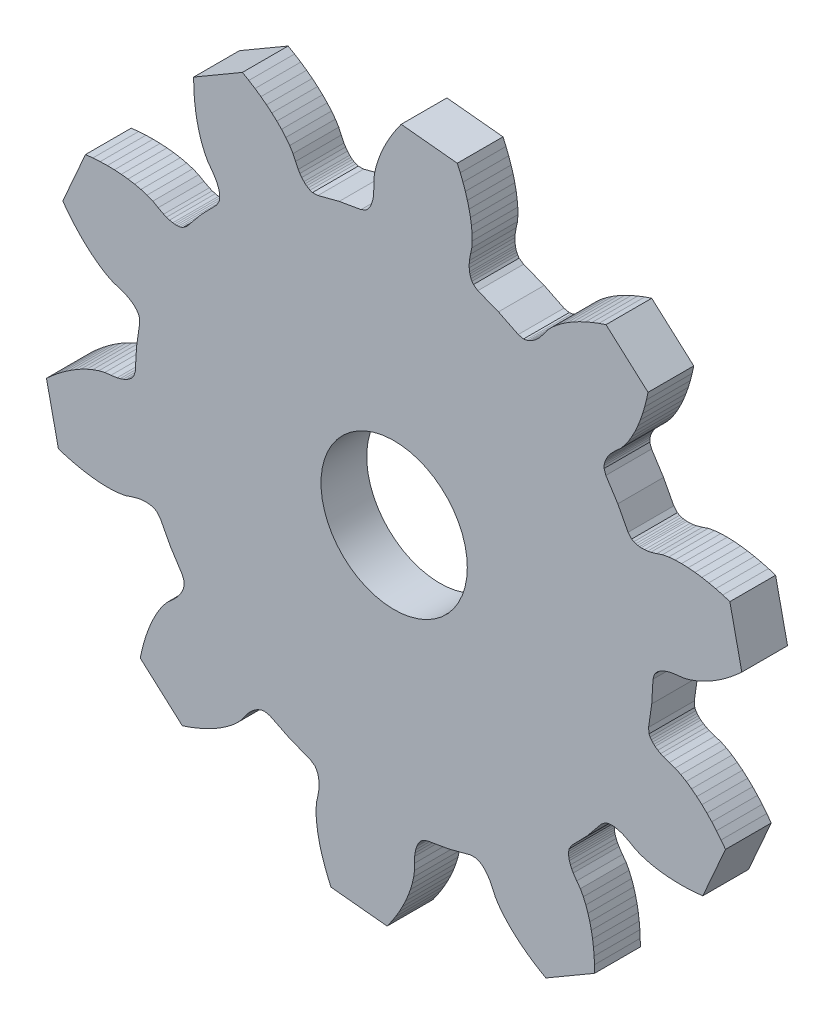
from build123d import *

# Parameters (mm, degrees)
SKETCH1_R           = 5.08
BOSS_EXTRUDE1_DEPTH = 3.175


with BuildPart() as part:
    # Sketch1 → Boss-Extrude1 (new body)
    with BuildSketch(Plane.XY):
        Polygon((8.111998, 16.660876), (7.864348, 16.943578), (7.710424, 17.02816), (7.572502, 17.077944), (7.443216, 17.108932), (7.319772, 17.127474), (7.200392, 17.136618), (6.97103, 17.133824), (6.750812, 17.109948), (6.537198, 17.069816), (6.126226, 16.951198), (5.722366, 16.815308), (5.295138, 16.737584), (4.853432, 16.697452), (4.400804, 16.687546), (3.93954, 16.704564), (3.470402, 16.746474), (2.994914, 16.812006), (2.514092, 16.900144), (2.02819, 17.010888), (1.538478, 17.143222), (1.045718, 17.297146), (0.215646, 21.122894), (0.600456, 21.467064), (0.991362, 21.79066), (1.387602, 22.092412), (1.788668, 22.37232), (2.194306, 22.62886), (2.603754, 22.86127), (3.016758, 23.068026), (3.43281, 23.246334), (3.851402, 23.392892), (4.27228, 23.499318), (4.696206, 23.543006), (5.119624, 23.605236), (5.330444, 23.657052), (5.540756, 23.726902), (5.750814, 23.819358), (5.855462, 23.87727), (5.960364, 23.945088), (6.065012, 24.026876), (6.16966, 24.129492), (6.274816, 24.270208), (6.38302, 24.630126), (6.47192, 26.161238), (6.690614, 27.679396), (6.656578, 28.053538), (6.581648, 28.212542), (6.499352, 28.333954), (6.413246, 28.435046), (6.324092, 28.522422), (6.232906, 28.599892), (6.045708, 28.732734), (5.85343, 28.84297), (5.657342, 28.935934), (5.255006, 29.081476), (4.848352, 29.208984), (4.456938, 29.397198), (4.075938, 29.624528), (3.704082, 29.882338), (3.340862, 30.167326), (2.986024, 30.476698), (2.639822, 30.809184), (2.30251, 31.163514), (1.974596, 31.538418), (1.656334, 31.933388), (1.347978, 32.347662), (2.925318, 35.930586), (3.438906, 35.98291), (3.945128, 36.014914), (4.443222, 36.02609), (4.932172, 36.016692), (5.411216, 35.985958), (5.879084, 35.93338), (6.334506, 35.857688), (6.775958, 35.757612), (7.2009, 35.630104), (7.603998, 35.468814), (7.972552, 35.254946), (8.35152, 35.056572), (8.552688, 34.97453), (8.763762, 34.90722), (8.988044, 34.858706), (9.106916, 34.843974), (9.23163, 34.83737), (9.364472, 34.841942), (9.509506, 34.863278), (9.677146, 34.915348), (9.976358, 35.142932), (10.948162, 36.32962), (12.017502, 37.428932), (12.20978, 37.751766), (12.242546, 37.924486), (12.247372, 38.071044), (12.236958, 38.203378), (12.216384, 38.326568), (12.18819, 38.4429), (12.114784, 38.660324), (12.024106, 38.862508), (11.919966, 39.053008), (11.679936, 39.407084), (11.425936, 39.749476), (11.219942, 40.131746), (11.045444, 40.539416), (10.896092, 40.966644), (10.7696, 41.41089), (10.664444, 41.869868), (10.579862, 42.342308), (10.515346, 42.82694), (10.470388, 43.323256), (10.444988, 43.829732), (10.438892, 44.346114), (13.821156, 46.317662), (14.267434, 46.058074), (14.695678, 45.786294), (15.10538, 45.50283), (15.49527, 45.207682), (15.86484, 44.901358), (16.212312, 44.583604), (16.536416, 44.254674), (16.834866, 43.914314), (17.103344, 43.561508), (17.334738, 43.19397), (17.507204, 42.804334), (17.697196, 42.421048), (17.81175, 42.23639), (17.943068, 42.057828), (18.095976, 41.886886), (18.183352, 41.805098), (18.28038, 41.726358), (18.390616, 41.65219), (18.52041, 41.584118), (18.68678, 41.527476), (19.062446, 41.535858), (20.54606, 41.924732), (22.057614, 42.18559), (22.403054, 42.333672), (22.530816, 42.454068), (22.620986, 42.569892), (22.690328, 42.683176), (22.746208, 42.794936), (22.791674, 42.905426), (22.86, 43.124628), (22.905466, 43.34129), (22.933152, 43.556936), (22.947376, 43.984418), (22.942804, 44.41063), (23.00097, 44.840906), (23.099522, 45.273468), (23.229824, 45.706792), (23.388574, 46.14037), (23.573232, 46.57344), (23.782528, 47.005494), (24.015192, 47.43577), (24.270462, 47.863506), (24.547576, 48.288194), (24.84628, 48.70958), (28.74137, 48.316642), (28.949904, 47.844202), (29.136594, 47.372524), (29.30144, 46.90237), (29.443426, 46.434502), (29.562298, 45.969428), (29.656786, 45.508164), (29.72562, 45.051472), (29.766768, 44.600876), (29.776674, 44.157392), (29.747972, 43.724068), (29.65831, 43.307508), (29.586936, 42.885614), (29.570934, 42.668952), (29.572204, 42.447464), (29.595572, 42.219118), (29.617924, 42.10177), (29.650436, 41.98112), (29.695648, 41.856152), (29.760926, 41.724834), (29.862272, 41.581324), (30.170882, 41.367202), (31.599886, 40.809672), (32.976058, 40.132508), (33.34258, 40.049196), (33.516824, 40.071294), (33.65754, 40.112188), (33.780476, 40.162988), (33.89122, 40.220646), (33.993074, 40.283384), (34.17697, 40.42029), (34.341308, 40.569134), (34.490406, 40.727122), (34.753042, 41.064688), (34.99993, 41.411906), (35.300158, 41.726104), (35.633914, 42.01795), (35.994086, 42.292016), (36.377372, 42.549572), (36.781486, 42.79138), (37.20465, 43.017948), (37.645594, 43.229022), (38.103556, 43.42511), (38.57752, 43.605958), (39.066724, 43.771058), (41.986962, 41.163748), (41.877996, 40.65905), (41.752012, 40.167814), (41.608756, 39.690548), (41.448736, 39.228522), (41.271444, 38.782498), (41.07688, 38.353746), (40.864282, 37.94379), (40.632634, 37.554916), (40.380158, 37.190426), (40.102028, 36.85667), (39.784528, 36.57219), (39.478712, 36.273232), (39.338758, 36.107116), (39.209472, 35.927284), (39.094156, 35.72891), (39.043102, 35.620452), (38.998398, 35.503866), (38.961822, 35.376358), (38.937184, 35.231832), (38.934898, 35.056064), (39.05885, 34.701226), (39.887144, 33.410398), (40.602408, 32.05353), (40.850058, 31.770828), (41.003982, 31.686246), (41.141904, 31.636462), (41.27119, 31.605474), (41.394634, 31.586932), (41.51376, 31.577788), (41.743376, 31.580582), (41.963594, 31.604458), (42.177208, 31.64459), (42.58818, 31.763208), (42.99204, 31.899098), (43.419268, 31.976822), (43.860974, 32.016954), (44.313602, 32.02686), (44.774866, 32.009842), (45.244004, 31.967932), (45.719492, 31.9024), (46.200314, 31.814008), (46.686216, 31.703518), (47.175928, 31.571184), (47.668688, 31.41726), (48.49876, 27.591512), (48.11395, 27.247342), (47.723044, 26.923746), (47.326804, 26.621994), (46.925738, 26.342086), (46.5201, 26.085546), (46.110652, 25.853136), (45.697648, 25.64638), (45.281596, 25.468072), (44.863004, 25.321514), (44.442126, 25.215088), (44.0182, 25.1714), (43.594782, 25.10917), (43.383962, 25.0571), (43.17365, 24.987504), (42.963592, 24.895048), (42.858944, 24.837136), (42.754042, 24.769318), (42.649394, 24.68753), (42.544492, 24.584914), (42.43959, 24.444198), (42.331386, 24.08428), (42.242486, 22.553168), (42.023792, 21.03501), (42.057828, 20.660614), (42.132758, 20.501864), (42.215054, 20.380452), (42.30116, 20.27936), (42.390314, 20.191984), (42.4815, 20.114514), (42.668698, 19.981672), (42.860976, 19.871436), (43.057064, 19.778472), (43.4594, 19.63293), (43.866054, 19.505422), (44.257468, 19.317208), (44.638468, 19.089878), (45.010324, 18.832068), (45.373544, 18.54708), (45.728382, 18.237454), (46.074584, 17.904968), (46.411896, 17.550892), (46.73981, 17.175988), (47.058072, 16.781018), (47.366428, 16.366744), (45.789088, 12.78382), (45.2755, 12.731496), (44.769278, 12.699492), (44.271184, 12.688062), (43.782234, 12.697714), (43.30319, 12.728448), (42.835322, 12.781026), (42.3799, 12.856718), (41.938448, 12.956794), (41.513506, 13.084302), (41.110408, 13.245592), (40.741854, 13.45946), (40.362886, 13.657834), (40.161718, 13.739876), (39.95039, 13.807186), (39.726108, 13.8557), (39.60749, 13.870432), (39.482776, 13.877036), (39.349934, 13.872464), (39.2049, 13.851128), (39.03726, 13.799058), (38.738048, 13.571474), (37.766244, 12.384786), (36.696904, 11.285474), (36.504626, 10.96264), (36.47186, 10.78992), (36.467034, 10.643362), (36.477448, 10.511028), (36.498022, 10.387838), (36.526216, 10.271506), (36.599622, 10.054082), (36.6903, 9.851898), (36.79444, 9.661398), (37.03447, 9.307068), (37.28847, 8.96493), (37.494464, 8.58266), (37.668962, 8.17499), (37.818314, 7.747762), (37.944806, 7.303516), (38.049962, 6.844538), (38.134544, 6.372098), (38.19906, 5.887466), (38.244018, 5.39115), (38.269418, 4.884674), (38.275514, 4.368292), (34.89325, 2.396744), (34.446972, 2.656332), (34.018728, 2.928112), (33.609026, 3.211576), (33.219136, 3.506724), (32.849566, 3.813048), (32.502094, 4.130802), (32.17799, 4.459732), (31.87954, 4.800092), (31.610808, 5.152898), (31.379668, 5.520436), (31.206948, 5.910072), (31.01721, 6.293358), (30.902656, 6.478016), (30.771338, 6.656578), (30.61843, 6.82752), (30.531054, 6.909308), (30.434026, 6.988048), (30.32379, 7.062216), (30.193996, 7.130288), (30.027626, 7.18693), (29.65196, 7.178548), (28.168346, 6.789674), (26.656792, 6.528816), (26.311352, 6.380734), (26.18359, 6.260338), (26.09342, 6.144514), (26.024078, 6.03123), (25.968198, 5.91947), (25.922732, 5.80898), (25.854406, 5.589778), (25.80894, 5.372862), (25.781254, 5.15747), (25.76703, 4.729988), (25.771602, 4.303776), (25.713436, 3.8735), (25.614884, 3.440938), (25.484582, 3.007614), (25.325832, 2.574036), (25.141174, 2.140966), (24.931878, 1.708912), (24.699214, 1.278636), (24.443944, 0.8509), (24.16683, 0.426212), (23.868126, 0.004826), (19.973036, 0.397764), (19.764502, 0.870204), (19.577812, 1.341882), (19.412966, 1.812036), (19.27098, 2.279904), (19.152108, 2.744978), (19.05762, 3.206242), (18.988786, 3.662934), (18.947638, 4.11353), (18.937478, 4.557014), (18.966434, 4.990338), (19.055842, 5.406898), (19.12747, 5.828792), (19.143472, 6.045454), (19.142202, 6.266942), (19.118834, 6.495288), (19.096482, 6.612636), (19.06397, 6.733286), (19.018758, 6.858254), (18.95348, 6.989572), (18.852134, 7.133082), (18.54327, 7.347204), (17.11452, 7.904734), (15.738348, 8.581898), (15.371826, 8.66521), (15.197582, 8.643112), (15.056866, 8.602218), (14.93393, 8.551418), (14.823186, 8.49376), (14.721332, 8.431022), (14.537182, 8.294116), (14.373098, 8.145272), (14.224, 7.987284), (13.961364, 7.649718), (13.714476, 7.302246), (13.414248, 6.988302), (13.080492, 6.696456), (12.72032, 6.42239), (12.337034, 6.164834), (11.93292, 5.923026), (11.509756, 5.696458), (11.068812, 5.485384), (10.61085, 5.289296), (10.136886, 5.108448), (9.647682, 4.943348), (6.727444, 7.550658), (6.83641, 8.055356), (6.962394, 8.546592), (7.10565, 9.023858), (7.26567, 9.485884), (7.442962, 9.931908), (7.637526, 10.36066), (7.850124, 10.770616), (8.081772, 11.15949), (8.334248, 11.52398), (8.612378, 11.857736), (8.929624, 12.142216), (9.235694, 12.441174), (9.375648, 12.60729), (9.504934, 12.787122), (9.62025, 12.985496), (9.67105, 13.093954), (9.716008, 13.21054), (9.752584, 13.338048), (9.777222, 13.482574), (9.779508, 13.658342), (9.655556, 14.01318), (8.827262, 15.304008), align=None)
        with Locations((24.357076, 24.357076)):
            Circle(SKETCH1_R, mode=Mode.SUBTRACT)
    extrude(amount=BOSS_EXTRUDE1_DEPTH)


solid = part.part
